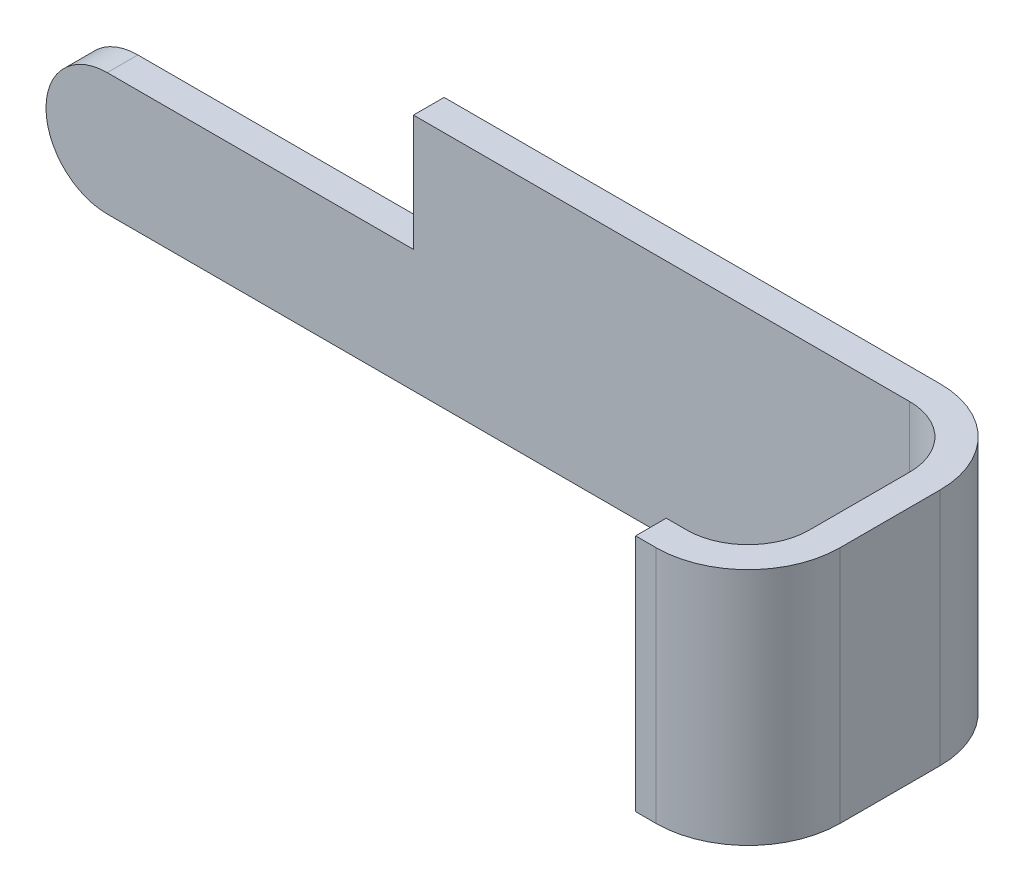
from build123d import *

# Parameters (mm, degrees)
EXTRUDE_1_DEPTH = 0.25
SKETCH_2_W      = 4.8
SKETCH_2_H      = 0.25
EXTRUDE_2_DEPTH = 0.95
SKETCH_3_W      = 0.25
SKETCH_3_H      = 1.95
EXTRUDE_3_DEPTH = 2.068252296
SKETCH_4_W      = 0.25
SKETCH_4_H      = 1.95
EXTRUDE_4_DEPTH = 0.668252296
FILLET_1_R      = 0.5
FILLET_2_R      = 0.75


with BuildPart() as part:
    # 草图1 → 凸台-拉伸1 (new body)
    with BuildSketch(Plane(origin=(0, 0, -0.25), x_dir=(-1, 0, 0), z_dir=(0, 0, -1))):
        with BuildLine():
            Line((0.486013986, 1), (-6.813986014, 1))
            Line((-6.813986014, 1), (-6.813986014, 0))
            Line((-6.813986014, 0), (0.486013986, 0))
            ThreePointArc((0.486013986, 0), (0.986013986, 0.5), (0.486013986, 1))
        make_face()
    extrude(amount=-EXTRUDE_1_DEPTH)

    # 草图2 → 凸台-拉伸2 (add)
    with BuildSketch(Plane(origin=(0, 1, 0), x_dir=(-1, 0, 0), z_dir=(0, 1, 0))):
        with Locations((-4.413986014, -0.125)):
            Rectangle(SKETCH_2_W, SKETCH_2_H)
    extrude(amount=EXTRUDE_2_DEPTH)

    # 草图3 → 凸台-拉伸3 (add)
    with BuildSketch(Plane.XY):
        with Locations((6.688986014, 0.975)):
            Rectangle(SKETCH_3_W, SKETCH_3_H)
    extrude(amount=EXTRUDE_3_DEPTH)

    # 草图4 → 凸台-拉伸4 (add)
    with BuildSketch(Plane.ZY.offset(-6.563986014)):
        with Locations((1.943252296, 0.975)):
            Rectangle(SKETCH_4_W, SKETCH_4_H)
    extrude(amount=EXTRUDE_4_DEPTH)

    # 圆角1
    fillet_1_edges = [part.edges().sort_by_distance(p)[0] for p in [
        (6.563986014, 0.975, 0),
        (6.563986014, 0.975, 1.818252296),
    ]]
    fillet(fillet_1_edges, radius=FILLET_1_R)

    # 圆角2
    fillet_2_edges = [part.edges().sort_by_distance(p)[0] for p in [
        (6.813986014, 0.975, 2.068252296),
        (6.813986014, 0.975, -0.25),
    ]]
    fillet(fillet_2_edges, radius=FILLET_2_R)


solid = part.part
